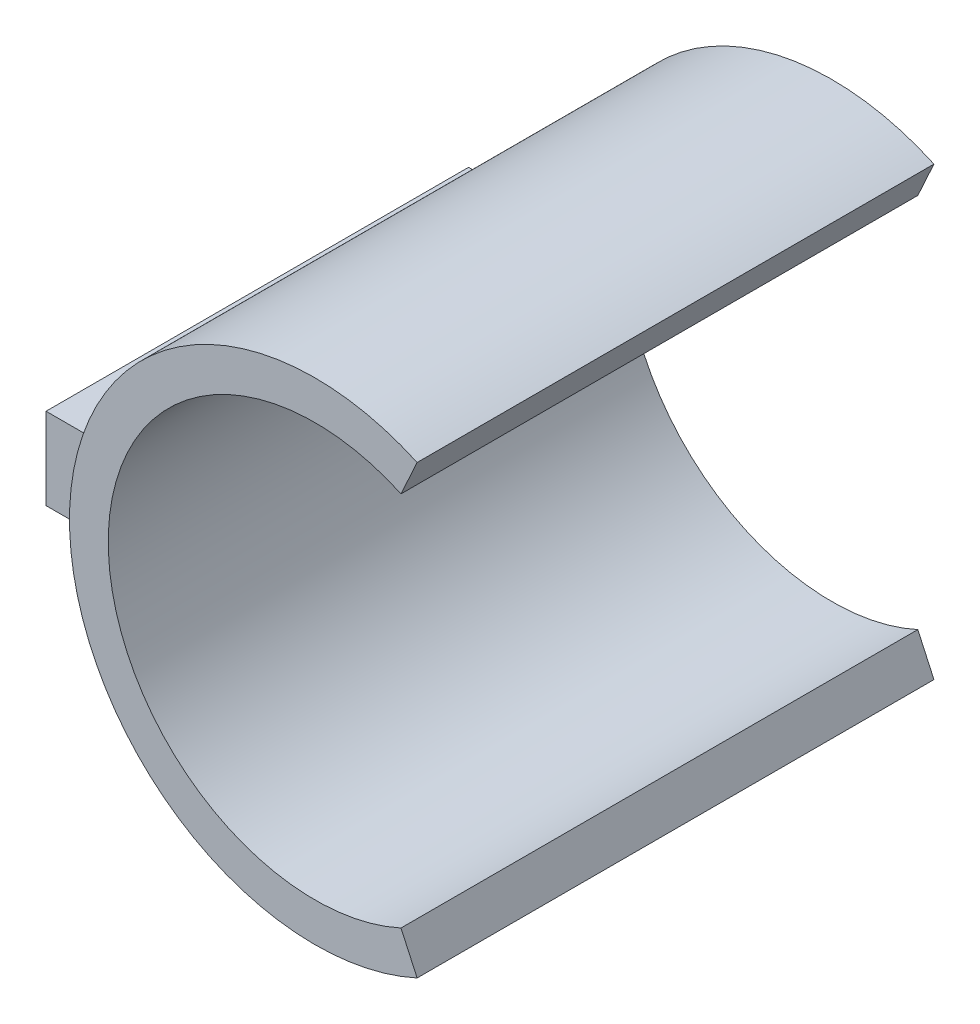
from build123d import *

# Parameters (mm, degrees)
SKETCH1_R           = 4.75
SKETCH1_R_2         = 4
BOSS_EXTRUDE1_DEPTH = 10
CUT_EXTRUDE2_DEPTH  = 10
SKETCH4_W           = 8.174166442
SKETCH4_H           = 1.582309943
BOSS_EXTRUDE2_DEPTH = 1.5


with BuildPart() as part:
    # Sketch1 → Boss-Extrude1 (new body)
    with BuildSketch(Plane.XY):
        Circle(SKETCH1_R)
        Circle(SKETCH1_R_2, mode=Mode.SUBTRACT)
    extrude(amount=BOSS_EXTRUDE1_DEPTH)

    # Sketch3 → Cut-Extrude2 (cut)
    with BuildSketch(Plane.XY.offset(10)):
        with BuildLine():
            ThreePointArc((1.66450103, 3.637229209), (3.365858295, 2.161249162), (4, 0))
            Line((4, 0), (4.75, 0))
            ThreePointArc((4.75, 0), (4.749994219, 0.007410728), (4.749976876, 0.014821438))
            ThreePointArc((4.749976876, 0.014821438), (3.992947753, 2.572716122), (1.976594973, 4.319209686))
            Line((1.976594973, 4.319209686), (1.66450103, 3.637229209))
        make_face()
        with BuildLine():
            Line((4.75, 0), (4, 0))
            ThreePointArc((4, 0), (3.365858295, -2.161249162), (1.66450103, -3.637229209))
            Line((1.66450103, -3.637229209), (1.976594973, -4.319209686))
            ThreePointArc((1.976594973, -4.319209686), (3.996956725, -2.56648338), (4.75, 0))
        make_face()
    extrude(amount=-CUT_EXTRUDE2_DEPTH, mode=Mode.SUBTRACT)

    # Sketch4 → Boss-Extrude2 (add)
    with BuildSketch(Plane(origin=(-4.5, 0, 0), x_dir=(0, 0, -1), z_dir=(1, 0, 0))):
        with Locations((-5.116351143, 0.000178202)):
            Rectangle(SKETCH4_W, SKETCH4_H)
    extrude(amount=-BOSS_EXTRUDE2_DEPTH)


solid = part.part
